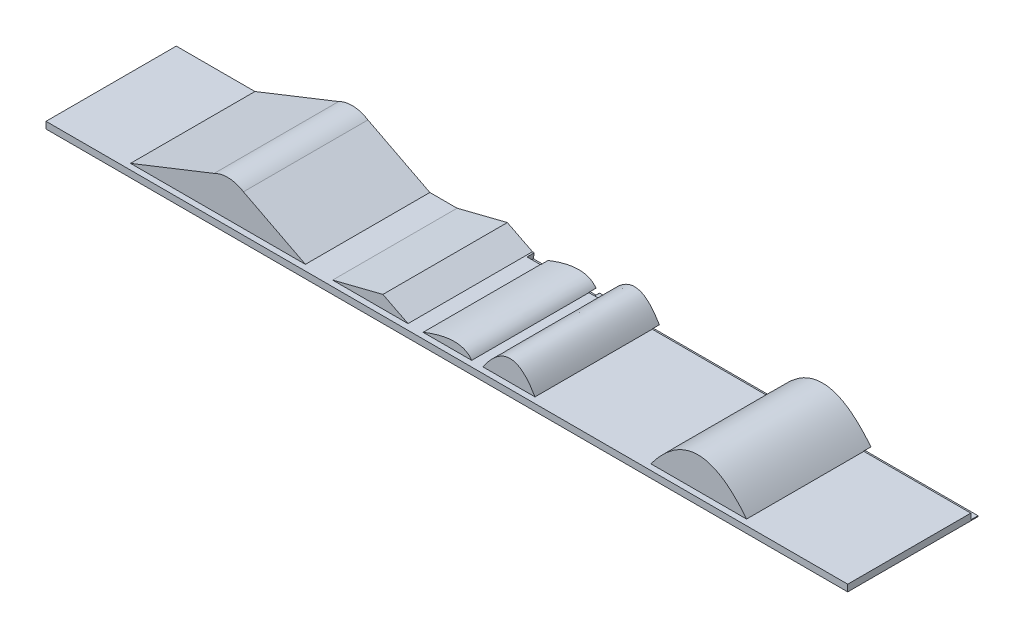
from build123d import *

# Parameters (mm, degrees)
SKETCH1_W           = 4000
SKETCH1_H           = 650
BOSS_EXTRUDE1_DEPTH = 300
CUT_EXTRUDE3_DEPTH  = 333
CUT_EXTRUDE4_DEPTH  = 333
SKETCH7_W           = 4176.612748617
SKETCH7_H           = 878.539936904
CUT_EXTRUDE5_DEPTH  = 1765
BOSS_EXTRUDE2_DEPTH = 621
CUT_EXTRUDE2_DEPTH  = 36
SKETCH9_W           = 176.354899095
SKETCH9_H           = 70.962636727
CUT_EXTRUDE6_DEPTH  = 1243


with BuildPart() as part:
    # Sketch1 → Boss-Extrude1 (new body)
    with BuildSketch(Plane(origin=(0, 0, 0), x_dir=(1, 0, 0), z_dir=(0, 1, 0))):
        Rectangle(SKETCH1_W, SKETCH1_H)
    extrude(amount=BOSS_EXTRUDE1_DEPTH)

    # Sketch4 → Cut-Extrude3 (cut)
    with BuildSketch(Plane.XY.offset(325)):
        with BuildLine():
            Line((-2000, 42), (-1023.920441049, 42))
            add(Edge.make_bspline(
                [(-1023.920441049, 42), (-625.596073389, 421.290119466), (-564.500559645, 42), (-394.069004627, 42)],
                knots=[0, 0, 0, 0, 1, 1, 1, 1], degree=3))
            Line((-394.069004627, 42), (77.281429251, 42))
            add(Edge.make_bspline(
                [(77.281429251, 42), (384.820845821, 379.875880114), (804.142903292, 42.162527318)],
                knots=[0, 0, 0, 1, 1, 1], degree=2))
            add(Edge.make_bspline(
                [(804.142903292, 42.162527318), (1120.560926985, 359.520052232), (1155.923131209, 42), (1331.813245168, 42)],
                knots=[0, 0, 0, 0, 1, 1, 1, 1], degree=3))
            Line((1331.813245168, 42), (2000, 42))
            Line((2000, 42), (2000, 300))
            Line((2000, 300), (-2000, 300))
            Line((-2000, 300), (-2000, 42))
        make_face()
    extrude(amount=-CUT_EXTRUDE3_DEPTH, mode=Mode.SUBTRACT)

    # Sketch6 → Cut-Extrude4 (cut)
    with BuildSketch(Plane(origin=(0, 0, -325), x_dir=(-1, 0, 0), z_dir=(0, 0, -1))):
        with BuildLine():
            Line((-2000, 42), (-1446.05727282, 42))
            add(Edge.make_bspline(
                [(-1446.05727282, 42), (-1028.485172915, 427.490568143), (-723.10412717, 43.749887322)],
                knots=[0, 0, 0, 1, 1, 1], degree=2))
            Line((-723.10412717, 43.749887322), (89.99607078, 43.749887322))
            add(Edge.make_bspline(
                [(89.99607078, 43.749887322), (269.67433471, 358.502210653), (843.089835557, 43.749887322)],
                knots=[0, 0, 0, 1, 1, 1], degree=2))
            add(Edge.make_bspline(
                [(843.089835557, 43.749887322), (1192.189018248, 462.039061907), (1476.297158589, 43.749887322)],
                knots=[0, 0, 0, 1, 1, 1], degree=2))
            Line((1476.297158589, 43.749887322), (2000, 42))
            Line((2000, 42), (2000, 300))
            Line((2000, 300), (-2000, 300))
            Line((-2000, 300), (-2000, 42))
        make_face()
    extrude(amount=-CUT_EXTRUDE4_DEPTH, mode=Mode.SUBTRACT)

    # Sketch7 → Cut-Extrude5 (cut)
    with BuildSketch(Plane.XY.offset(325)):
        with Locations((88.306374309, 472.795361716)):
            Rectangle(SKETCH7_W, SKETCH7_H)
    extrude(amount=-CUT_EXTRUDE5_DEPTH, mode=Mode.SUBTRACT)

    # Sketch8 → Boss-Extrude2 (add)
    with BuildSketch(Plane(origin=(0, 0, -325), x_dir=(-1, 0, 0), z_dir=(0, 0, -1))):
        with BuildLine():
            Line((-1466.411502922, 33.525393264), (-988.607191526, 33.525393264))
            add(Edge.make_bspline(
                [(-988.607191526, 33.525393264), (-1220.104325428, 346.541530652), (-1466.411502922, 33.525393264)],
                knots=[0, 0, 0, 1, 1, 1], degree=2))
        make_face()
        with BuildLine():
            Line((-410.743928037, 33.525393264), (-151.038080393, 33.525393264))
            add(Edge.make_bspline(
                [(-410.743928037, 33.525393264), (-291.466535424, 240.977763656), (-151.038080393, 33.525393264)],
                knots=[0, 0, 0, 1, 1, 1], degree=2))
        make_face()
        with BuildLine():
            Line((-615.129598905, 33.525393264), (-449.639529972, 33.525393264))
            add(Edge.make_bspline(
                [(-615.129598905, 33.525393264), (-519.506305291, 140.143472245), (-449.639529972, 33.525393264)],
                knots=[0, 0, 0, 1, 1, 1], degree=2))
        make_face()
        with BuildLine():
            Line((-94.943921992, 33.525393264), (147.62807094, 33.525393264))
            add(Edge.make_bspline(
                [(-94.943921992, 33.525393264), (-41.784880201, 109.912399552), (147.62807094, 33.525393264)],
                knots=[0, 0, 0, 1, 1, 1], degree=2))
        make_face()
        Polygon((348.198866267, 96.926617606), (222.810217102, 33.525393264), (598.976164599, 33.525393264), align=None)
        with BuildLine():
            Line((1043.880942781, 192.333296754), (734.829470359, 33.525393264))
            Line((734.829470359, 33.525393264), (1607.487691917, 33.525393264))
            Line((1607.487691917, 33.525393264), (1190.091100426, 198.921972194))
            ThreePointArc((1190.091100426, 198.921972194), (1116.100399875, 215.280581972), (1043.880942781, 192.333296754))
        make_face()
    extrude(amount=-BOSS_EXTRUDE2_DEPTH)

    # Sketch3 → Cut-Extrude2 (cut)
    with BuildSketch(Plane(origin=(0, 0, -325), x_dir=(-1, 0, 0), z_dir=(0, 0, -1))):
        with BuildLine():
            Line((-2000, 4.395124569), (-154.790798, 4.395124569))
            add(Edge.make_bspline(
                [(-154.790798, 4.395124569), (-122.121165819, 28.84941573), (-111.562876496, 29.486117766), (-96.041953686, 4.767611069)],
                knots=[0, 0, 0, 0, 1, 1, 1, 1], degree=3))
            Line((-96.041953686, 4.767611069), (24.286817383, 4.767611069))
            add(Edge.make_bspline(
                [(24.286817383, 4.767611069), (43.520377225, 22.639006885), (73.620382864, 4.582969303)],
                knots=[0, 0, 0, 1, 1, 1], degree=2))
            add(Edge.make_bspline(
                [(73.620382864, 4.582969303), (101.904065398, 17.027789618), (102.645412237, 9.528187349), (123.323430354, 0.559894652), (134.386420176, 12.839234646), (142.868415145, 5.48817234)],
                knots=[0, 0, 0, 0, 0.498478211, 0.598478211, 1, 1, 1, 1], degree=3))
            Line((142.868415145, 5.48817234), (218.45286868, 5.48817234))
            Line((218.45286868, 5.48817234), (213.926853499, 34.454669503))
            Line((213.926853499, 34.454669503), (-2000, 34.454669503))
            Line((-2000, 34.454669503), (-2000, 4.395124569))
        make_face()
    extrude(amount=-CUT_EXTRUDE2_DEPTH, mode=Mode.SUBTRACT)

    # Sketch9 → Cut-Extrude6 (cut)
    with BuildSketch(Plane(origin=(0, 0, -325), x_dir=(-1, 0, 0), z_dir=(0, 0, -1))):
        with Locations((-526.952149358, 69.006711628)):
            Rectangle(SKETCH9_W, SKETCH9_H)
    extrude(amount=-CUT_EXTRUDE6_DEPTH, mode=Mode.SUBTRACT)


solid = part.part
